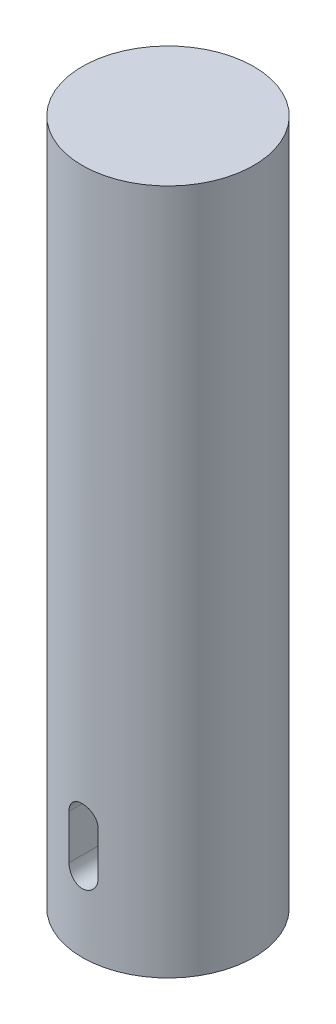
from build123d import *

# Parameters (mm, degrees)
SKIZZE1_R                       = 25
AUFSATZ_LINEAR_AUSTRAGEN1_DEPTH = 200
SCHNITT_LINEAR_AUSTRAGEN1_DEPTH = 10


with BuildPart() as part:
    # Skizze1 → Aufsatz-Linear austragen1 (new body)
    with BuildSketch(Plane(origin=(0, 0, 0), x_dir=(1, 0, 0), z_dir=(0, 1, 0))):
        with Locations(Location((0, 0, 0), (0, 0, 270))):  # turned: the seam where the file's is
            Circle(SKIZZE1_R)
    extrude(amount=AUFSATZ_LINEAR_AUSTRAGEN1_DEPTH)

    # Skizze2 → Schnitt-Linear austragen1 (cut)
    with BuildSketch(Plane.XY.offset(25)):
        with BuildLine():
            Line((-4.234822954, 21.641230775), (-4.234822954, 34.628021169))
            ThreePointArc((-4.234822954, 34.628021169), (0, 38.862844123), (4.234822954, 34.628021169))
            Line((4.234822954, 34.628021169), (4.234822954, 21.641230775))
            ThreePointArc((4.234822954, 21.641230775), (0, 17.406407821), (-4.234822954, 21.641230775))
        make_face()
    extrude(amount=-SCHNITT_LINEAR_AUSTRAGEN1_DEPTH, mode=Mode.SUBTRACT)


solid = part.part
